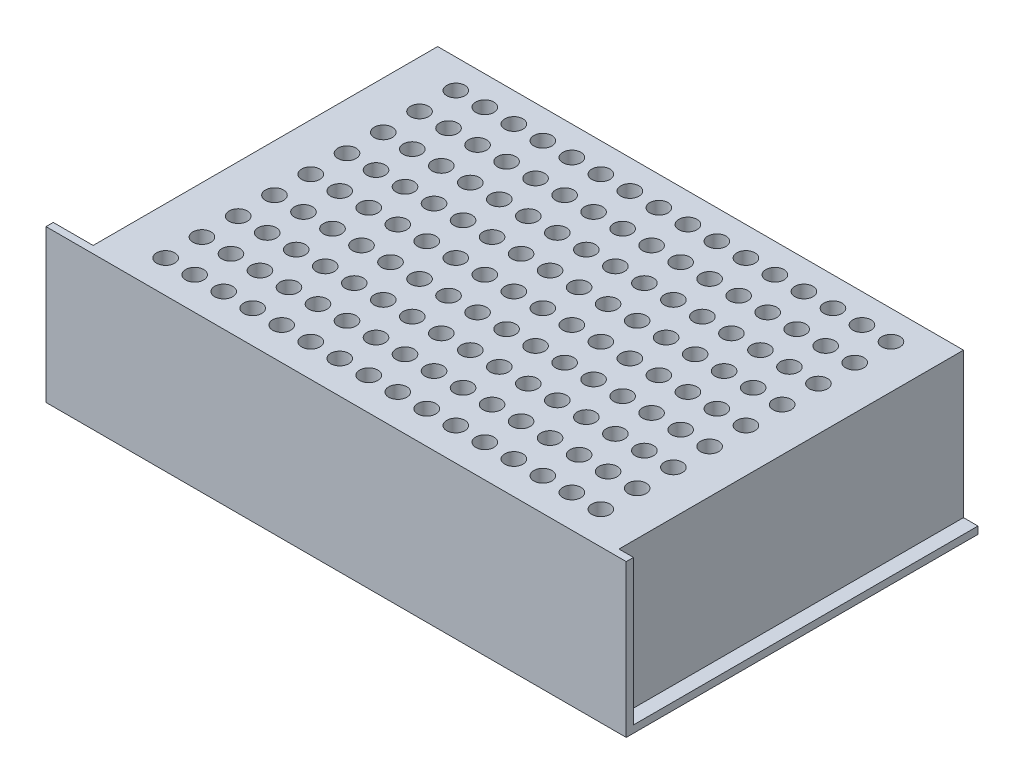
from build123d import *

# Parameters (mm, degrees)
EXTRUDE_1_DEPTH        = 160
SKETCH_3_W             = 145
SKETCH_3_H             = 95
EXTRUDE_2_DEPTH        = 40
SKETCH_4_R             = 2.5
CUT_EXTRUDE_1_DEPTH    = 20
SKETCH_5_W             = 69
SKETCH_5_H             = 17
EXTRUDE_3_DEPTH        = 12
SKETCH_6_R             = 1.5
CUT_EXTRUDE_2719_DEPTH = 12


with BuildPart() as part:
    # 草图2 → 凸台-拉伸1 (new body)
    with BuildSketch(Plane(origin=(0, 0, 0), x_dir=(0, 0, -1), z_dir=(1, 0, 0))):
        Polygon((0, 0), (-97, 0), (-97, 42), (-95, 42), (-95, 2), (0, 2), align=None)
    extrude(amount=EXTRUDE_1_DEPTH)

    # 草图3 → 凸台-拉伸2 (add)
    with BuildSketch(Plane(origin=(0, 2, 0), x_dir=(1, 0, 0), z_dir=(0, 1, 0))):
        with Locations((83.5, -47.5)):
            Rectangle(SKETCH_3_W, SKETCH_3_H)
    extrude(amount=EXTRUDE_2_DEPTH)

    # 草图4 → 切除-拉伸1 (cut)
    with BuildSketch(Plane(origin=(0, 42, 0), x_dir=(1, 0, 0), z_dir=(0, 1, 0))):
        with Locations((24, -8)):
            Circle(SKETCH_4_R)
        with Locations((32, -8)):
            Circle(SKETCH_4_R)
        with Locations((40, -8)):
            Circle(SKETCH_4_R)
        with Locations((48, -8)):
            Circle(SKETCH_4_R)
        with Locations((56, -8)):
            Circle(SKETCH_4_R)
        with Locations((64, -8)):
            Circle(SKETCH_4_R)
        with Locations((72, -8)):
            Circle(SKETCH_4_R)
        with Locations((80, -8)):
            Circle(SKETCH_4_R)
        with Locations((88, -8)):
            Circle(SKETCH_4_R)
        with Locations((96, -8)):
            Circle(SKETCH_4_R)
        with Locations((104, -8)):
            Circle(SKETCH_4_R)
        with Locations((112, -8)):
            Circle(SKETCH_4_R)
        with Locations((120, -8)):
            Circle(SKETCH_4_R)
        with Locations((128, -8)):
            Circle(SKETCH_4_R)
        with Locations((136, -8)):
            Circle(SKETCH_4_R)
        with Locations((144, -8)):
            Circle(SKETCH_4_R)
        with Locations((32, -18)):
            Circle(SKETCH_4_R)
        with Locations((40, -18)):
            Circle(SKETCH_4_R)
        with Locations((48, -18)):
            Circle(SKETCH_4_R)
        with Locations((56, -18)):
            Circle(SKETCH_4_R)
        with Locations((64, -18)):
            Circle(SKETCH_4_R)
        with Locations((72, -18)):
            Circle(SKETCH_4_R)
        with Locations((80, -18)):
            Circle(SKETCH_4_R)
        with Locations((88, -18)):
            Circle(SKETCH_4_R)
        with Locations((96, -18)):
            Circle(SKETCH_4_R)
        with Locations((104, -18)):
            Circle(SKETCH_4_R)
        with Locations((112, -18)):
            Circle(SKETCH_4_R)
        with Locations((120, -18)):
            Circle(SKETCH_4_R)
        with Locations((128, -18)):
            Circle(SKETCH_4_R)
        with Locations((136, -18)):
            Circle(SKETCH_4_R)
        with Locations((144, -18)):
            Circle(SKETCH_4_R)
        with Locations((32, -28)):
            Circle(SKETCH_4_R)
        with Locations((40, -28)):
            Circle(SKETCH_4_R)
        with Locations((48, -28)):
            Circle(SKETCH_4_R)
        with Locations((56, -28)):
            Circle(SKETCH_4_R)
        with Locations((64, -28)):
            Circle(SKETCH_4_R)
        with Locations((72, -28)):
            Circle(SKETCH_4_R)
        with Locations((80, -28)):
            Circle(SKETCH_4_R)
        with Locations((88, -28)):
            Circle(SKETCH_4_R)
        with Locations((96, -28)):
            Circle(SKETCH_4_R)
        with Locations((104, -28)):
            Circle(SKETCH_4_R)
        with Locations((112, -28)):
            Circle(SKETCH_4_R)
        with Locations((120, -28)):
            Circle(SKETCH_4_R)
        with Locations((128, -28)):
            Circle(SKETCH_4_R)
        with Locations((136, -28)):
            Circle(SKETCH_4_R)
        with Locations((144, -28)):
            Circle(SKETCH_4_R)
        with Locations((32, -38)):
            Circle(SKETCH_4_R)
        with Locations((40, -38)):
            Circle(SKETCH_4_R)
        with Locations((48, -38)):
            Circle(SKETCH_4_R)
        with Locations((56, -38)):
            Circle(SKETCH_4_R)
        with Locations((64, -38)):
            Circle(SKETCH_4_R)
        with Locations((72, -38)):
            Circle(SKETCH_4_R)
        with Locations((80, -38)):
            Circle(SKETCH_4_R)
        with Locations((88, -38)):
            Circle(SKETCH_4_R)
        with Locations((96, -38)):
            Circle(SKETCH_4_R)
        with Locations((104, -38)):
            Circle(SKETCH_4_R)
        with Locations((112, -38)):
            Circle(SKETCH_4_R)
        with Locations((120, -38)):
            Circle(SKETCH_4_R)
        with Locations((128, -38)):
            Circle(SKETCH_4_R)
        with Locations((136, -38)):
            Circle(SKETCH_4_R)
        with Locations((144, -38)):
            Circle(SKETCH_4_R)
        with Locations((32, -48)):
            Circle(SKETCH_4_R)
        with Locations((40, -48)):
            Circle(SKETCH_4_R)
        with Locations((48, -48)):
            Circle(SKETCH_4_R)
        with Locations((56, -48)):
            Circle(SKETCH_4_R)
        with Locations((64, -48)):
            Circle(SKETCH_4_R)
        with Locations((72, -48)):
            Circle(SKETCH_4_R)
        with Locations((80, -48)):
            Circle(SKETCH_4_R)
        with Locations((88, -48)):
            Circle(SKETCH_4_R)
        with Locations((96, -48)):
            Circle(SKETCH_4_R)
        with Locations((104, -48)):
            Circle(SKETCH_4_R)
        with Locations((112, -48)):
            Circle(SKETCH_4_R)
        with Locations((120, -48)):
            Circle(SKETCH_4_R)
        with Locations((128, -48)):
            Circle(SKETCH_4_R)
        with Locations((136, -48)):
            Circle(SKETCH_4_R)
        with Locations((144, -48)):
            Circle(SKETCH_4_R)
        with Locations((32, -58)):
            Circle(SKETCH_4_R)
        with Locations((40, -58)):
            Circle(SKETCH_4_R)
        with Locations((48, -58)):
            Circle(SKETCH_4_R)
        with Locations((56, -58)):
            Circle(SKETCH_4_R)
        with Locations((64, -58)):
            Circle(SKETCH_4_R)
        with Locations((72, -58)):
            Circle(SKETCH_4_R)
        with Locations((80, -58)):
            Circle(SKETCH_4_R)
        with Locations((88, -58)):
            Circle(SKETCH_4_R)
        with Locations((96, -58)):
            Circle(SKETCH_4_R)
        with Locations((104, -58)):
            Circle(SKETCH_4_R)
        with Locations((112, -58)):
            Circle(SKETCH_4_R)
        with Locations((120, -58)):
            Circle(SKETCH_4_R)
        with Locations((128, -58)):
            Circle(SKETCH_4_R)
        with Locations((136, -58)):
            Circle(SKETCH_4_R)
        with Locations((144, -58)):
            Circle(SKETCH_4_R)
        with Locations((32, -68)):
            Circle(SKETCH_4_R)
        with Locations((40, -68)):
            Circle(SKETCH_4_R)
        with Locations((48, -68)):
            Circle(SKETCH_4_R)
        with Locations((56, -68)):
            Circle(SKETCH_4_R)
        with Locations((64, -68)):
            Circle(SKETCH_4_R)
        with Locations((72, -68)):
            Circle(SKETCH_4_R)
        with Locations((80, -68)):
            Circle(SKETCH_4_R)
        with Locations((88, -68)):
            Circle(SKETCH_4_R)
        with Locations((96, -68)):
            Circle(SKETCH_4_R)
        with Locations((104, -68)):
            Circle(SKETCH_4_R)
        with Locations((112, -68)):
            Circle(SKETCH_4_R)
        with Locations((120, -68)):
            Circle(SKETCH_4_R)
        with Locations((128, -68)):
            Circle(SKETCH_4_R)
        with Locations((136, -68)):
            Circle(SKETCH_4_R)
        with Locations((144, -68)):
            Circle(SKETCH_4_R)
        with Locations((32, -78)):
            Circle(SKETCH_4_R)
        with Locations((40, -78)):
            Circle(SKETCH_4_R)
        with Locations((48, -78)):
            Circle(SKETCH_4_R)
        with Locations((56, -78)):
            Circle(SKETCH_4_R)
        with Locations((64, -78)):
            Circle(SKETCH_4_R)
        with Locations((72, -78)):
            Circle(SKETCH_4_R)
        with Locations((80, -78)):
            Circle(SKETCH_4_R)
        with Locations((88, -78)):
            Circle(SKETCH_4_R)
        with Locations((96, -78)):
            Circle(SKETCH_4_R)
        with Locations((104, -78)):
            Circle(SKETCH_4_R)
        with Locations((112, -78)):
            Circle(SKETCH_4_R)
        with Locations((120, -78)):
            Circle(SKETCH_4_R)
        with Locations((128, -78)):
            Circle(SKETCH_4_R)
        with Locations((136, -78)):
            Circle(SKETCH_4_R)
        with Locations((144, -78)):
            Circle(SKETCH_4_R)
        with Locations((32, -88)):
            Circle(SKETCH_4_R)
        with Locations((40, -88)):
            Circle(SKETCH_4_R)
        with Locations((48, -88)):
            Circle(SKETCH_4_R)
        with Locations((56, -88)):
            Circle(SKETCH_4_R)
        with Locations((64, -88)):
            Circle(SKETCH_4_R)
        with Locations((72, -88)):
            Circle(SKETCH_4_R)
        with Locations((80, -88)):
            Circle(SKETCH_4_R)
        with Locations((88, -88)):
            Circle(SKETCH_4_R)
        with Locations((96, -88)):
            Circle(SKETCH_4_R)
        with Locations((104, -88)):
            Circle(SKETCH_4_R)
        with Locations((112, -88)):
            Circle(SKETCH_4_R)
        with Locations((120, -88)):
            Circle(SKETCH_4_R)
        with Locations((128, -88)):
            Circle(SKETCH_4_R)
        with Locations((136, -88)):
            Circle(SKETCH_4_R)
        with Locations((144, -88)):
            Circle(SKETCH_4_R)
        with Locations((24, -18)):
            Circle(SKETCH_4_R)
        with Locations((24, -28)):
            Circle(SKETCH_4_R)
        with Locations((24, -38)):
            Circle(SKETCH_4_R)
        with Locations((24, -48)):
            Circle(SKETCH_4_R)
        with Locations((24, -58)):
            Circle(SKETCH_4_R)
        with Locations((24, -68)):
            Circle(SKETCH_4_R)
        with Locations((24, -78)):
            Circle(SKETCH_4_R)
        with Locations((24, -88)):
            Circle(SKETCH_4_R)
    extrude(amount=-CUT_EXTRUDE_1_DEPTH, mode=Mode.SUBTRACT)

    # 草图5 → 凸台-拉伸3 (add)
    with BuildSketch(Plane.ZY.offset(-11)):
        with Locations((44.5, 19.336750857)):
            Rectangle(SKETCH_5_W, SKETCH_5_H)
    extrude(amount=EXTRUDE_3_DEPTH)

    # 草图6 → Cut-Extrude 2719 (cut)
    with BuildSketch(Plane.XZ):
        with Locations((102, 65)):
            Circle(SKETCH_6_R)
        with Locations((24, 65)):
            Circle(SKETCH_6_R)
    extrude(amount=-CUT_EXTRUDE_2719_DEPTH, mode=Mode.SUBTRACT)


solid = part.part
